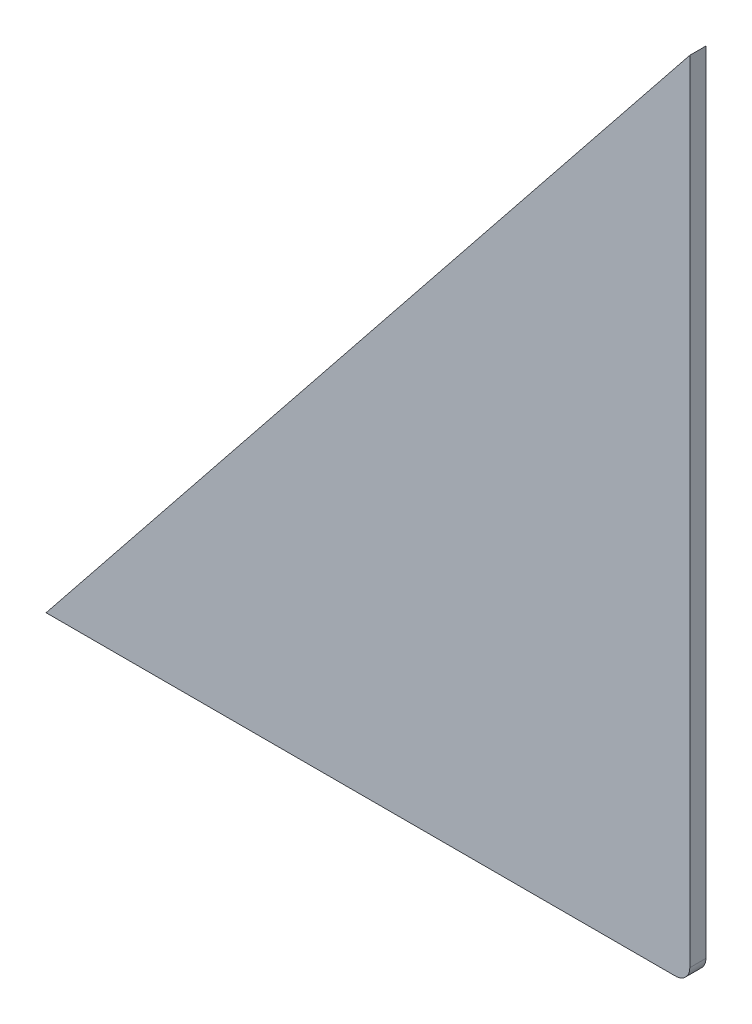
from build123d import *

# Parameters (mm, degrees)
BOSS_EXTRUDE1_DEPTH = 1


with BuildPart() as part:
    # Sketch1 → Boss-Extrude1 (new body, symmetric)
    with BuildSketch(Plane.XY):
        with BuildLine():
            Line((-80, 0), (-1.8, 0))
            ThreePointArc((-1.8, 0), (-0.527207794, 0.527207794), (0, 1.8))
            Line((0, 1.8), (0, 100))
            Line((0, 100), (-80, 0))
        make_face()
    extrude(amount=BOSS_EXTRUDE1_DEPTH, both=True)


solid = part.part
